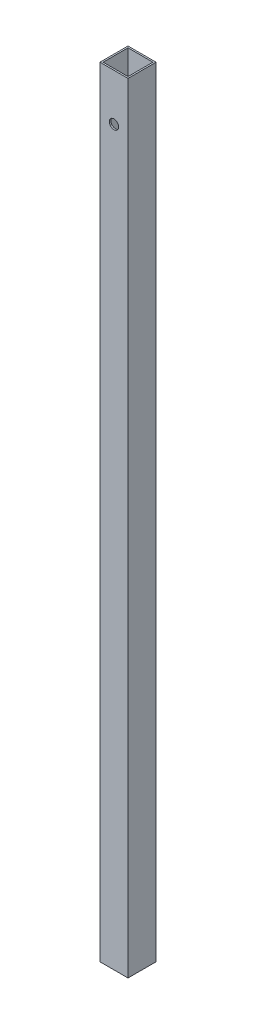
from build123d import *

# Parameters (mm, degrees)
SKETCH1_W           = 18
SKETCH1_H           = 18
SKETCH1_W_2         = 16
SKETCH1_H_2         = 16
BOSS_EXTRUDE1_DEPTH = 500
SKETCH2_R           = 3
CUT_EXTRUDE1_DEPTH  = 993


with BuildPart() as part:
    # Sketch1 → Boss-Extrude1 (new body)
    with BuildSketch(Plane(origin=(0, 0, 0), x_dir=(1, 0, 0), z_dir=(0, 1, 0))):
        Rectangle(SKETCH1_W, SKETCH1_H)
        Rectangle(SKETCH1_W_2, SKETCH1_H_2, mode=Mode.SUBTRACT)
    extrude(amount=BOSS_EXTRUDE1_DEPTH)

    # Sketch2 → Cut-Extrude1 (cut)
    with BuildSketch(Plane.XY.offset(9)):
        with Locations((0, 470)):
            Circle(SKETCH2_R)
    extrude(amount=-CUT_EXTRUDE1_DEPTH, mode=Mode.SUBTRACT)


solid = part.part
